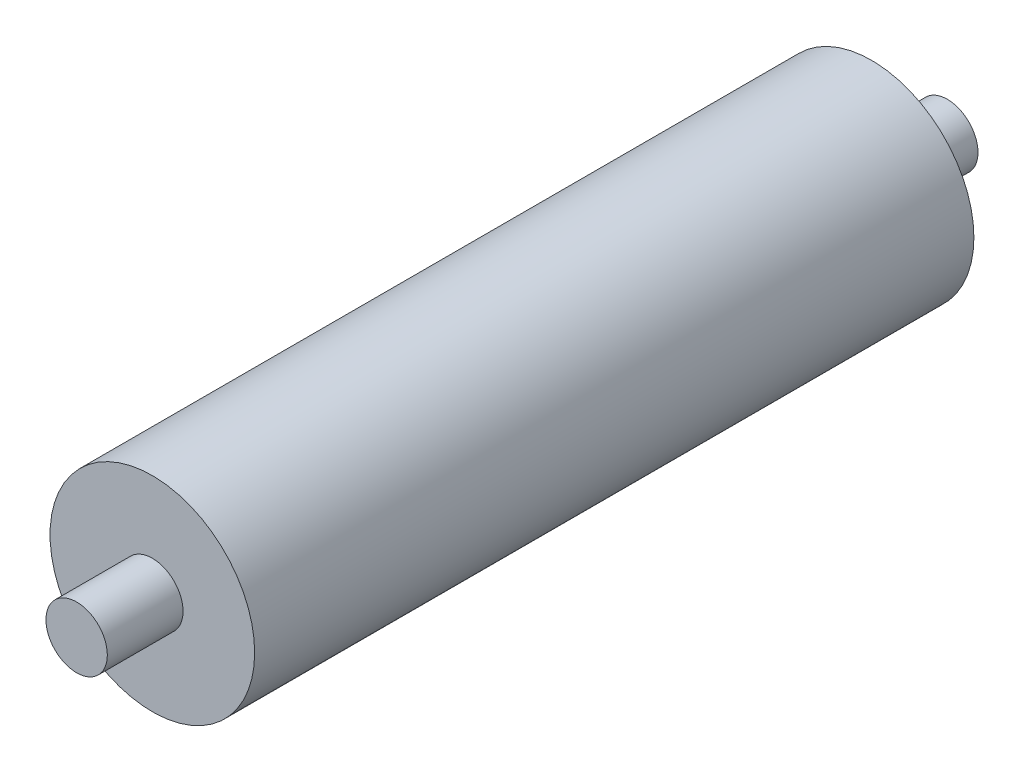
from build123d import *

# Parameters (mm, degrees)
SKETCH_1_R      = 5
EXTRUDE_1_DEPTH = 35.15
SKETCH_2_R      = 1.5
EXTRUDE_2_DEPTH = 3.7
SKETCH_3_R      = 1.5
EXTRUDE_3_DEPTH = 3.7


with BuildPart() as part:
    # 草图1 → 凸台-拉伸1 (new body)
    with BuildSketch(Plane.XY):
        Circle(SKETCH_1_R)
    extrude(amount=EXTRUDE_1_DEPTH)

    # 草图2 → 凸台-拉伸2 (add)
    with BuildSketch(Plane(origin=(0, 0, 0), x_dir=(-1, 0, 0), z_dir=(0, 0, -1))):
        Circle(SKETCH_2_R)
    extrude(amount=EXTRUDE_2_DEPTH)

    # 草图3 → 凸台-拉伸3 (add)
    with BuildSketch(Plane.XY.offset(35.15)):
        Circle(SKETCH_3_R)
    extrude(amount=EXTRUDE_3_DEPTH)


solid = part.part
